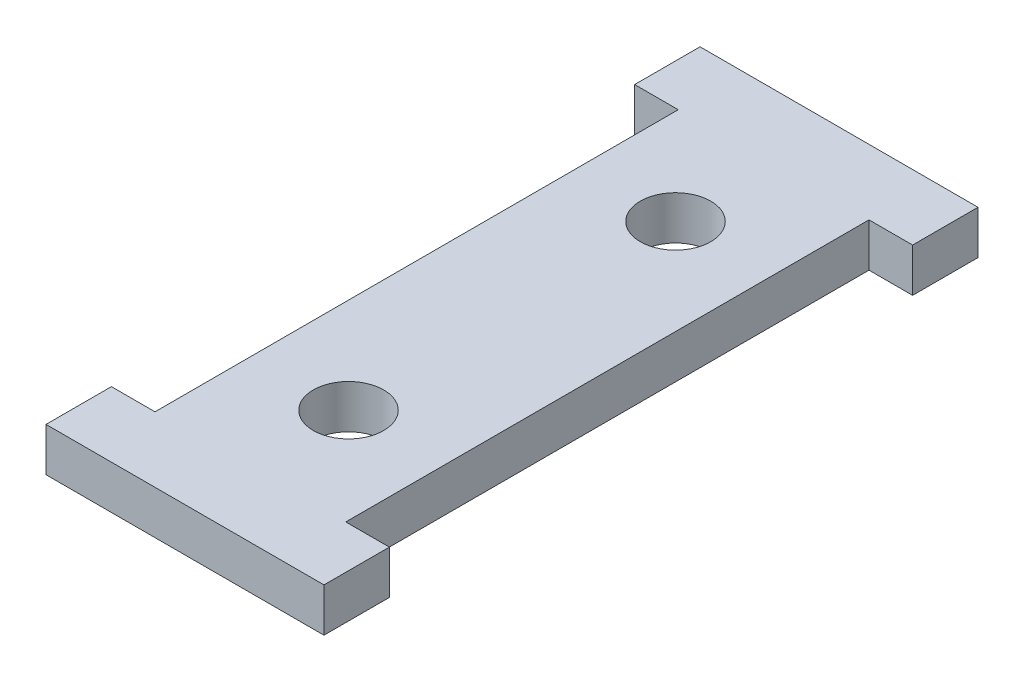
from build123d import *

# Parameters (mm, degrees)
BOSS_EXTRUDE1_DEPTH          = 5.08
P_0_323_DIAMETER_HOLE1_D     = 8.2042
P_0_323_DIAMETER_HOLE1_DEPTH = 16.51
P_0_323_DIAMETER_HOLE1_TIP   = 2.464790345


with BuildPart() as part:
    # Sketch1 → Boss-Extrude1 (new body)
    with BuildSketch(Plane(origin=(0, 0, 0), x_dir=(1, 0, 0), z_dir=(0, 1, 0))):
        Polygon((-16.1925, 0), (16.1925, 0), (16.1925, 7.62), (11.1125, 7.62), (11.1125, 68.58), (16.1925, 68.58), (16.1925, 76.2), (-16.1925, 76.2), (-16.1925, 68.58), (-11.1125, 68.58), (-11.1125, 7.62), (-16.1925, 7.62), align=None)
    extrude(amount=BOSS_EXTRUDE1_DEPTH)

    # P (0.323) Diameter Hole1
    with Locations(Plane(origin=(0, 5.08, 0), x_dir=(1, 0, 0), z_dir=(0, 1, 0))):
        with Locations((0, 57.15), (0, 19.05)):
            Hole(P_0_323_DIAMETER_HOLE1_D / 2, depth=P_0_323_DIAMETER_HOLE1_DEPTH)
            with Locations((0, 0, -(P_0_323_DIAMETER_HOLE1_DEPTH + P_0_323_DIAMETER_HOLE1_TIP / 2))):  # 118° drill point
                Cone(0, P_0_323_DIAMETER_HOLE1_D / 2, P_0_323_DIAMETER_HOLE1_TIP, mode=Mode.SUBTRACT)


solid = part.part
